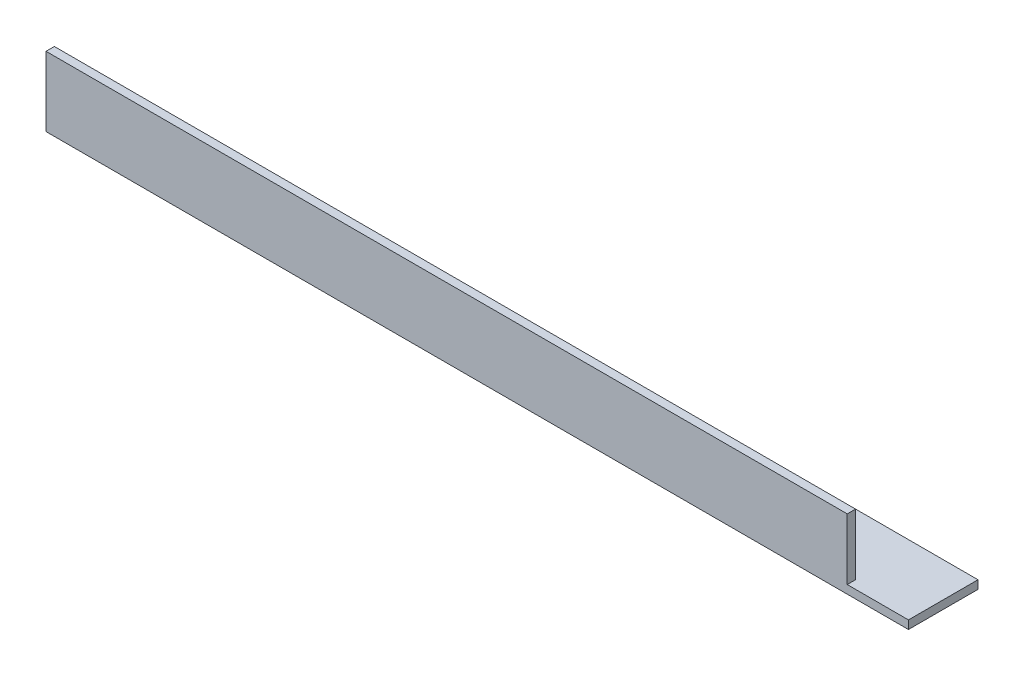
from build123d import *

# Parameters (mm, degrees)
EXTRUDE_1_DEPTH     = 310
SKETCH_2_W          = 22
SKETCH_2_H          = 22
CUT_EXTRUDE_1_DEPTH = 26


with BuildPart() as part:
    # Эскиз1 → Вытянуть-Тонкостенный1 (new body)
    with BuildSketch(Plane(origin=(0, 0, 0), x_dir=(0, 0, -1), z_dir=(1, 0, 0))):
        Polygon((0, 25), (0, 0), (25, 0), (25, 3), (3, 3), (3, 25), align=None)
    extrude(amount=EXTRUDE_1_DEPTH)

    # Эскиз2 → Вырез-Вытянуть1 (cut, through all)
    with BuildSketch(Plane.XY):
        with Locations((299, 14)):
            Rectangle(SKETCH_2_W, SKETCH_2_H)
    extrude(amount=-CUT_EXTRUDE_1_DEPTH, mode=Mode.SUBTRACT)


solid = part.part
